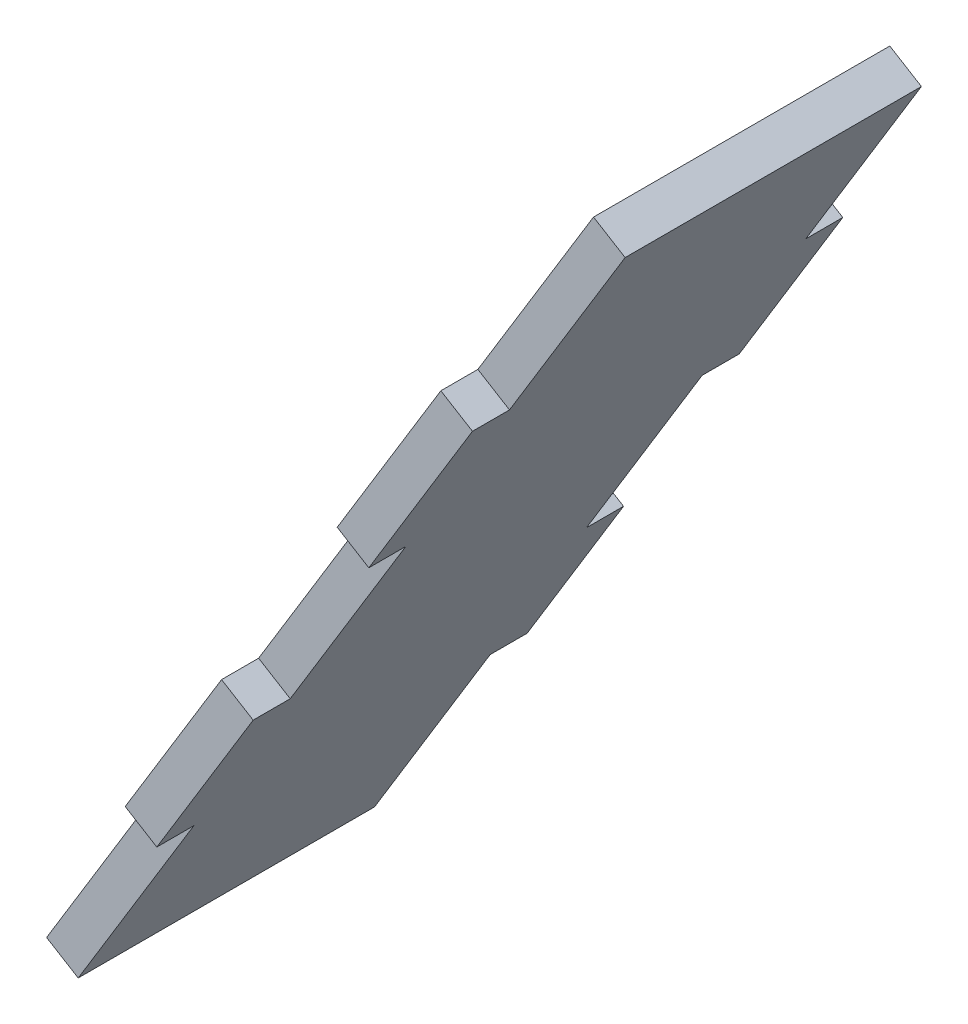
from build123d import *

# Parameters (mm, degrees)
BOSS_EXTRUDE1_DEPTH = 31.75
SKETCH3_W           = 3.175
SKETCH3_H           = 19.05
CUT_EXTRUDE1_DEPTH  = 3.175


with BuildPart() as part:
    # Sketch1 → Boss-Extrude1 (new body)
    with BuildSketch(Plane.XY):
        Polygon((423.30572032, 238.067163043), (470.193893436, 314.999977905), (472.905042097, 313.347616582), (426.01686898, 236.41480172), align=None)
    extrude(amount=-BOSS_EXTRUDE1_DEPTH)

    # Sketch3 → Cut-Extrude1 (cut)
    with BuildSketch(Plane(origin=(205.569888368, -125.288494, 0), x_dir=(0, 0, -1), z_dir=(0.85390509, -0.520428763, 0))):
        with Locations((1.5875, 504.157510823)):
            Rectangle(SKETCH3_W, SKETCH3_H)
        with Locations((30.1625, 504.157510823)):
            Rectangle(SKETCH3_W, SKETCH3_H)
        with Locations((1.5875, 433.112234694)):
            Rectangle(SKETCH3_W, SKETCH3_H)
        with Locations((30.1625, 433.112234694)):
            Rectangle(SKETCH3_W, SKETCH3_H)
        with Locations((30.1625, 468.037234694)):
            Rectangle(SKETCH3_W, SKETCH3_H)
        with Locations((1.5875, 468.037234694)):
            Rectangle(SKETCH3_W, SKETCH3_H)
    extrude(amount=-CUT_EXTRUDE1_DEPTH, mode=Mode.SUBTRACT)


solid = part.part
